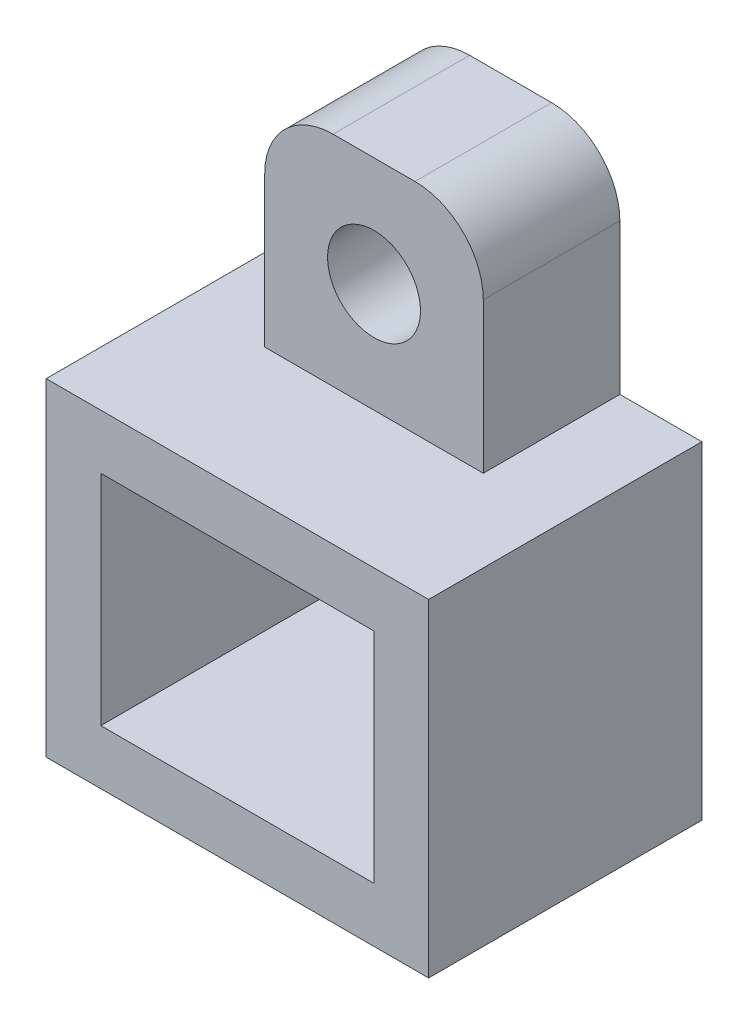
from build123d import *

# Parameters (mm, degrees)
SKETCH2_W           = 14
SKETCH2_H           = 12
BOSS_EXTRUDE1_DEPTH = 10
SKETCH1_W           = 10
SKETCH1_H           = 8
CUT_EXTRUDE2_DEPTH  = 11
SKETCH3_W           = 8
SKETCH3_H           = 8
BOSS_EXTRUDE2_DEPTH = 5
SKETCH4_R           = 1.7
CUT_EXTRUDE3_DEPTH  = 11
FILLET1_R           = 2.5


with BuildPart() as part:
    # Sketch2 → Boss-Extrude1 (new body)
    with BuildSketch(Plane.XY):
        Rectangle(SKETCH2_W, SKETCH2_H)
    extrude(amount=BOSS_EXTRUDE1_DEPTH)

    # Sketch1 → Cut-Extrude2 (cut, through all)
    with BuildSketch(Plane.XY):
        Rectangle(SKETCH1_W, SKETCH1_H)
    extrude(amount=CUT_EXTRUDE2_DEPTH, mode=Mode.SUBTRACT)

    # Sketch3 → Boss-Extrude2 (add)
    with BuildSketch(Plane.XY):
        with Locations((0, 10)):
            Rectangle(SKETCH3_W, SKETCH3_H)
    extrude(amount=BOSS_EXTRUDE2_DEPTH)

    # Sketch4 → Cut-Extrude3 (cut, through all)
    with BuildSketch(Plane.XY):
        with Locations((0, 10)):
            Circle(SKETCH4_R)
    extrude(amount=CUT_EXTRUDE3_DEPTH, mode=Mode.SUBTRACT)

    # Fillet1
    fillet1_edges = [part.edges().sort_by_distance(p)[0] for p in [
        (4, 14, 2.5),
        (-4, 14, 2.5),
    ]]
    fillet(fillet1_edges, radius=FILLET1_R)


solid = part.part
